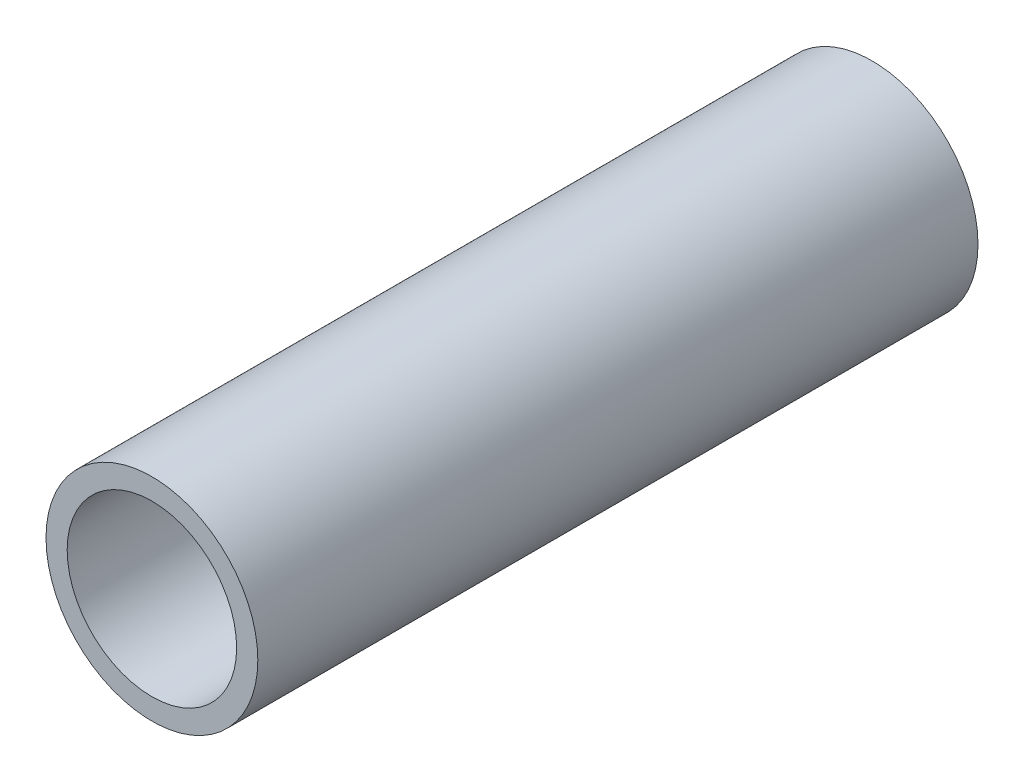
from build123d import *

# Parameters (mm, degrees)
SKETCH1_R           = 1.25
SKETCH1_R_2         = 1
TUBE_MCP_BODY_DEPTH = 8.5


with BuildPart() as part:
    # Sketch1 → Tube MCP Body (new body)
    with BuildSketch(Plane.XY):
        Circle(SKETCH1_R)
        Circle(SKETCH1_R_2, mode=Mode.SUBTRACT)
    extrude(amount=TUBE_MCP_BODY_DEPTH)


solid = part.part
